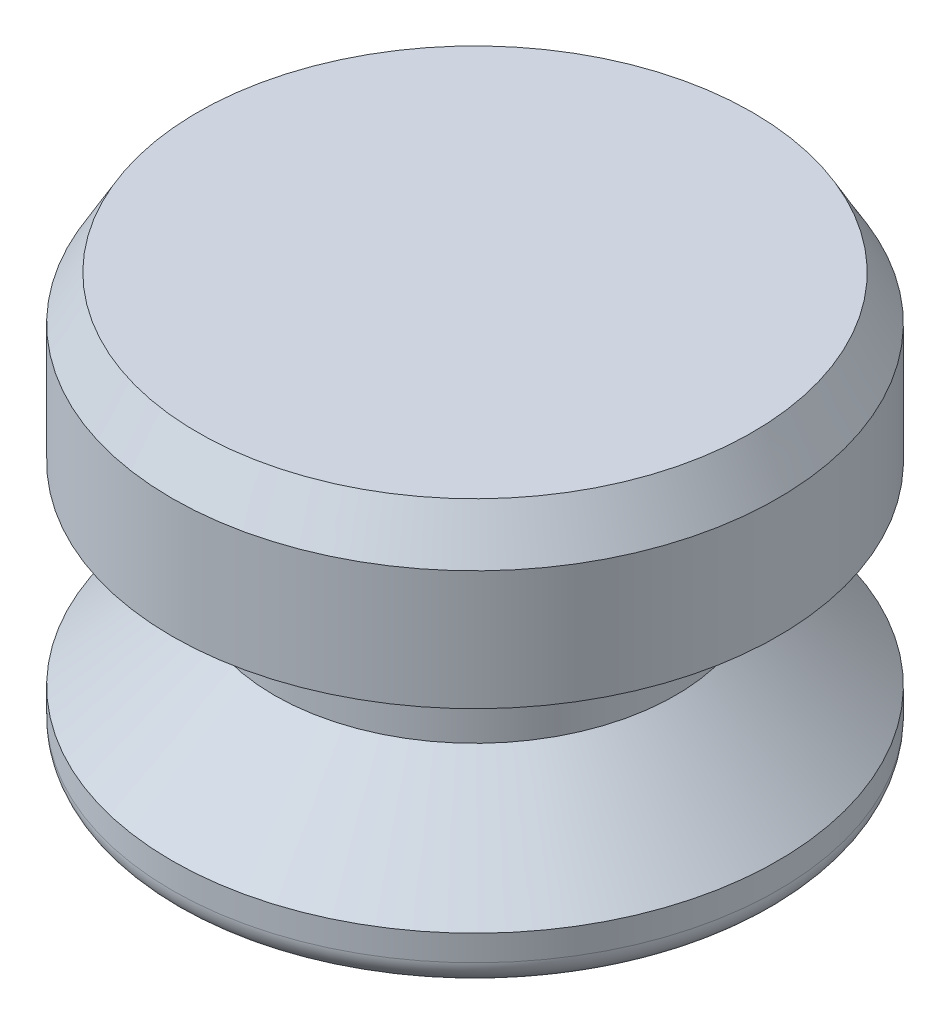
from build123d import *

# Parameters (mm, degrees)
FILLET1_R      = 0.79375
CHAMFER1_SIZE  = 0.79375
CHAMFER1_SIZE2 = 1.374815329


with BuildPart() as part:
    # Sketch1 → Revolve1 (revolve)
    with BuildSketch(Plane.XY):
        Polygon((0, 0), (-9.398, 0), (-9.398, 1.5875), (-6.223, 4.445), (-6.223, 7.62), (-9.398, 7.62), (-9.398, 12.7), (0, 12.7), align=None)
    revolve(axis=Axis((0, 0, 0), (0, 1, 0)))

    # Fillet1
    fillet1_edges = [part.edges().sort_by_distance(p)[0] for p in [
        (9.398, 0, 0),
    ]]
    fillet(fillet1_edges, radius=FILLET1_R)

    # Chamfer1
    chamfer1_edges = [part.edges().sort_by_distance(p)[0] for p in [
        (9.398, 12.7, 0),
    ]]
    chamfer1_side = [part.faces().sort_by_distance(p)[0] for p in [
        (0, 12.7, 0),
    ]]
    chamfer(chamfer1_edges, length=CHAMFER1_SIZE, length2=CHAMFER1_SIZE2, reference=chamfer1_side[0])


solid = part.part
